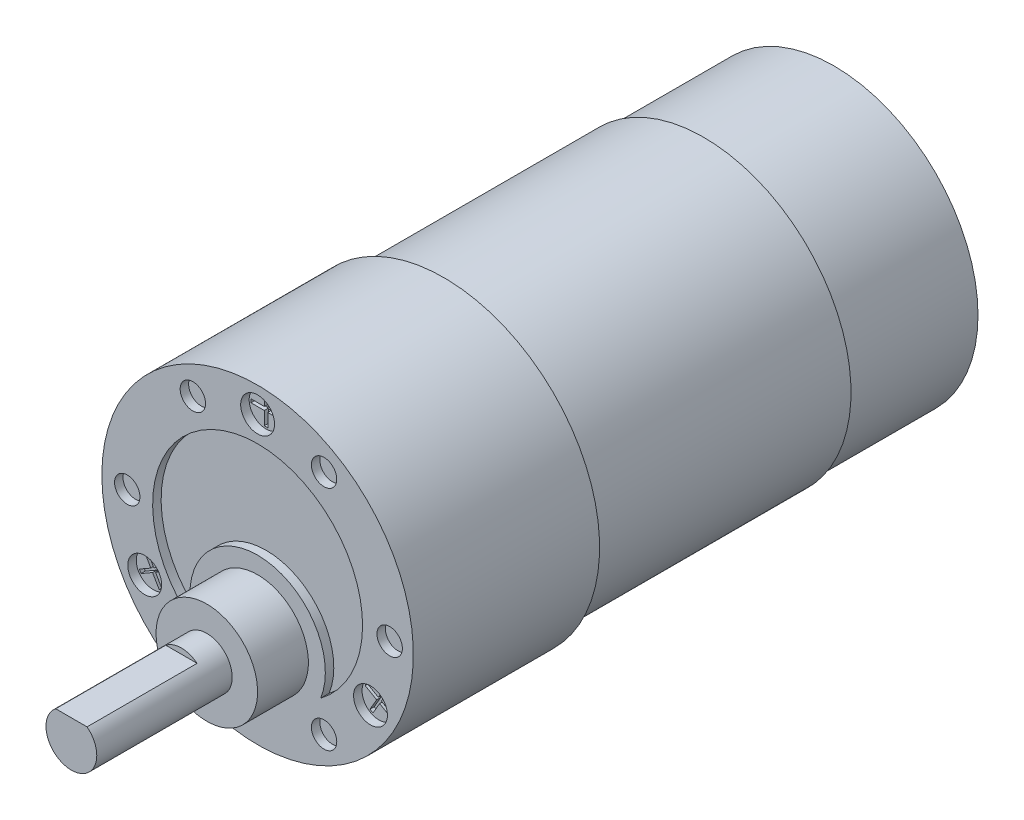
from build123d import *

# Parameters (mm, degrees)
SKETCH1_R           = 3
BOSS_EXTRUDE1_DEPTH = 16
CUT_EXTRUDE1_DEPTH  = 13
SKETCH4_R           = 6
BOSS_EXTRUDE2_DEPTH = 6
SKETCH5_R           = 18.4
BOSS_EXTRUDE3_DEPTH = 22
SKETCH6_R           = 17.4
BOSS_EXTRUDE4_DEPTH = 30.7
SKETCH7_R           = 17
BOSS_EXTRUDE5_DEPTH = 15.4
SKETCH8_R           = 2
SKETCH8_R_2         = 1.5
CUT_EXTRUDE2_DEPTH  = 1
CUT_EXTRUDE3_DEPTH  = 1
CUT_EXTRUDE4_DEPTH  = 0.5


with BuildPart() as part:
    # Sketch1 → Boss-Extrude1 (new body)
    with BuildSketch(Plane.XY):
        Circle(SKETCH1_R)
    extrude(amount=-BOSS_EXTRUDE1_DEPTH)

    # Sketch2 → Cut-Extrude1 (cut)
    with BuildSketch(Plane.XY):
        with BuildLine():
            Line((-1.854051563, 2.358493757), (1.854051563, 2.358493757))
            ThreePointArc((1.854051563, 2.358493757), (0, 3), (-1.854051563, 2.358493757))
        make_face()
    extrude(amount=-CUT_EXTRUDE1_DEPTH, mode=Mode.SUBTRACT)

    # Sketch4 → Boss-Extrude2 (add)
    with BuildSketch(Plane(origin=(0, 0, -16), x_dir=(-1, 0, 0), z_dir=(0, 0, -1))):
        Circle(SKETCH4_R)
    extrude(amount=BOSS_EXTRUDE2_DEPTH)

    # Sketch5 → Boss-Extrude3 (add)
    with BuildSketch(Plane(origin=(0, 0, -22), x_dir=(-1, 0, 0), z_dir=(0, 0, -1))):
        with Locations((0, 7)):
            Circle(SKETCH5_R)
    extrude(amount=BOSS_EXTRUDE3_DEPTH)

    # Sketch6 → Boss-Extrude4 (add)
    with BuildSketch(Plane(origin=(0, 0, -44), x_dir=(-1, 0, 0), z_dir=(0, 0, -1))):
        with Locations((0, 7)):
            Circle(SKETCH6_R)
    extrude(amount=BOSS_EXTRUDE4_DEPTH)

    # Sketch7 → Boss-Extrude5 (add)
    with BuildSketch(Plane(origin=(0, 0, -74.7), x_dir=(-1, 0, 0), z_dir=(0, 0, -1))):
        with Locations((0, 7)):
            Circle(SKETCH7_R)
    extrude(amount=BOSS_EXTRUDE5_DEPTH)

    # Sketch8 → Cut-Extrude2 (cut)
    with BuildSketch(Plane.XY.offset(-22)):
        with Locations((0, 22.4)):
            Circle(SKETCH8_R)
        with Locations((13.336791218, -0.7)):
            Circle(SKETCH8_R)
        with Locations((-13.336791218, -0.7)):
            Circle(SKETCH8_R)
        with Locations((-15.4, 7)):
            Circle(SKETCH8_R_2)
        with Locations((-7.65, 20.423393759)):
            Circle(SKETCH8_R_2)
        with Locations((7.85, 20.423393759)):
            Circle(SKETCH8_R_2)
        with Locations((15.6, 7)):
            Circle(SKETCH8_R_2)
        with Locations((7.85, -6.423393759)):
            Circle(SKETCH8_R_2)
        with Locations((-7.65, -6.423393759)):
            Circle(SKETCH8_R_2)
    extrude(amount=-CUT_EXTRUDE2_DEPTH, mode=Mode.SUBTRACT)

    # Sketch9 → Cut-Extrude3 (cut)
    with BuildSketch(Plane.XY.offset(-22)):
        with BuildLine():
            ThreePointArc((7.451414877, -2.911428571), (0, 8), (-7.451414877, -2.911428571))
            ThreePointArc((-7.451414877, -2.911428571), (0, 19.4), (7.451414877, -2.911428571))
        make_face()
    extrude(amount=-CUT_EXTRUDE3_DEPTH, mode=Mode.SUBTRACT)

    # Sketch10 → Cut-Extrude4 (cut)
    with BuildSketch(Plane.XY.offset(-23)):
        Polygon((0.198821757, 22.604844617), (1.765091395, 22.604844617), (1.765091395, 22.195155383), (0.198821757, 22.195155383), (0.198821757, 20.628885745), (-0.210867478, 20.628885745), (-0.210867478, 22.195155383), (-1.777137116, 22.195155383), (-1.777137116, 22.604844617), (-0.210867478, 22.604844617), (-0.210867478, 24.171114255), (0.198821757, 24.171114255), align=None)
        Polygon((13.414780982, -0.974607001), (12.631646163, -2.331036297), (12.276844878, -2.126191679), (13.059979697, -0.769762384), (11.703550402, 0.013372435), (11.908395019, 0.36817372), (13.264824315, -0.414961099), (14.047959134, 0.941468197), (14.402760419, 0.736623579), (13.6196256, -0.619805716), (14.976054895, -1.402940535), (14.771210278, -1.75774182), align=None)
        Polygon((-13.613602739, -0.630237616), (-14.396737558, 0.726191679), (-14.041936273, 0.931036297), (-13.258801454, -0.425392999), (-11.902372159, 0.35774182), (-11.697527541, 0.002940535), (-13.053956837, -0.780194284), (-12.270822018, -2.136623579), (-12.625623303, -2.341468197), (-13.408758122, -0.985038901), (-14.765187417, -1.76817372), (-14.970032035, -1.413372435), align=None)
    extrude(amount=-CUT_EXTRUDE4_DEPTH, mode=Mode.SUBTRACT)


solid = part.part
